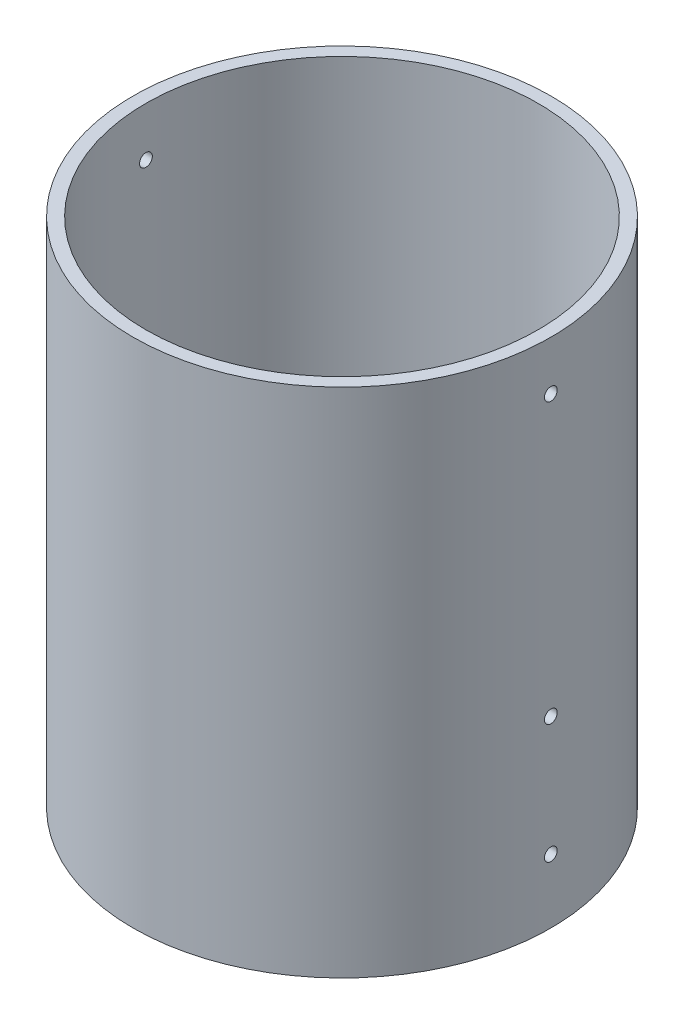
from build123d import *

# Parameters (mm, degrees)
SKETCH2_R               = 49
SKETCH2_R_2             = 46
BOSS_EXTRUDE1_DEPTH     = 120
SKETCH5_R               = 1.5
CUT_EXTRUDE2_DEPTH      = 50
CUT_EXTRUDE2_DEPTH_BACK = 50
SKETCH6_R               = 1.5
CUT_EXTRUDE3_DEPTH      = 50.0000001
CUT_EXTRUDE3_DEPTH_BACK = 50.000000102


with BuildPart() as part:
    # Sketch2 → Boss-Extrude1 (new body)
    with BuildSketch(Plane(origin=(0, 0, 0), x_dir=(1, 0, 0), z_dir=(0, 1, 0))):
        Circle(SKETCH2_R)
        Circle(SKETCH2_R_2, mode=Mode.SUBTRACT)
    extrude(amount=BOSS_EXTRUDE1_DEPTH)

    # Sketch5 → Cut-Extrude2 (cut, two sides)
    with BuildSketch(Plane(origin=(0, 0, 0), x_dir=(0, 0, -1), z_dir=(1, 0, 0))) as cut_extrude2_sk:
        with Locations((0, 108.5)):
            Circle(SKETCH5_R)
    extrude(amount=CUT_EXTRUDE2_DEPTH, mode=Mode.SUBTRACT)
    extrude(cut_extrude2_sk.sketch, amount=-CUT_EXTRUDE2_DEPTH_BACK, mode=Mode.SUBTRACT)

    # Sketch6 → Cut-Extrude3 (cut, two sides)
    with BuildSketch(Plane(origin=(0, 0, 0), x_dir=(0, 0, -1), z_dir=(1, 0, 0))) as cut_extrude3_sk:
        with Locations((0, 15)):
            Circle(SKETCH6_R)
        with Locations((0, 43)):
            Circle(SKETCH6_R)
    extrude(amount=CUT_EXTRUDE3_DEPTH, mode=Mode.SUBTRACT)
    extrude(cut_extrude3_sk.sketch, amount=-CUT_EXTRUDE3_DEPTH_BACK, mode=Mode.SUBTRACT)


solid = part.part
